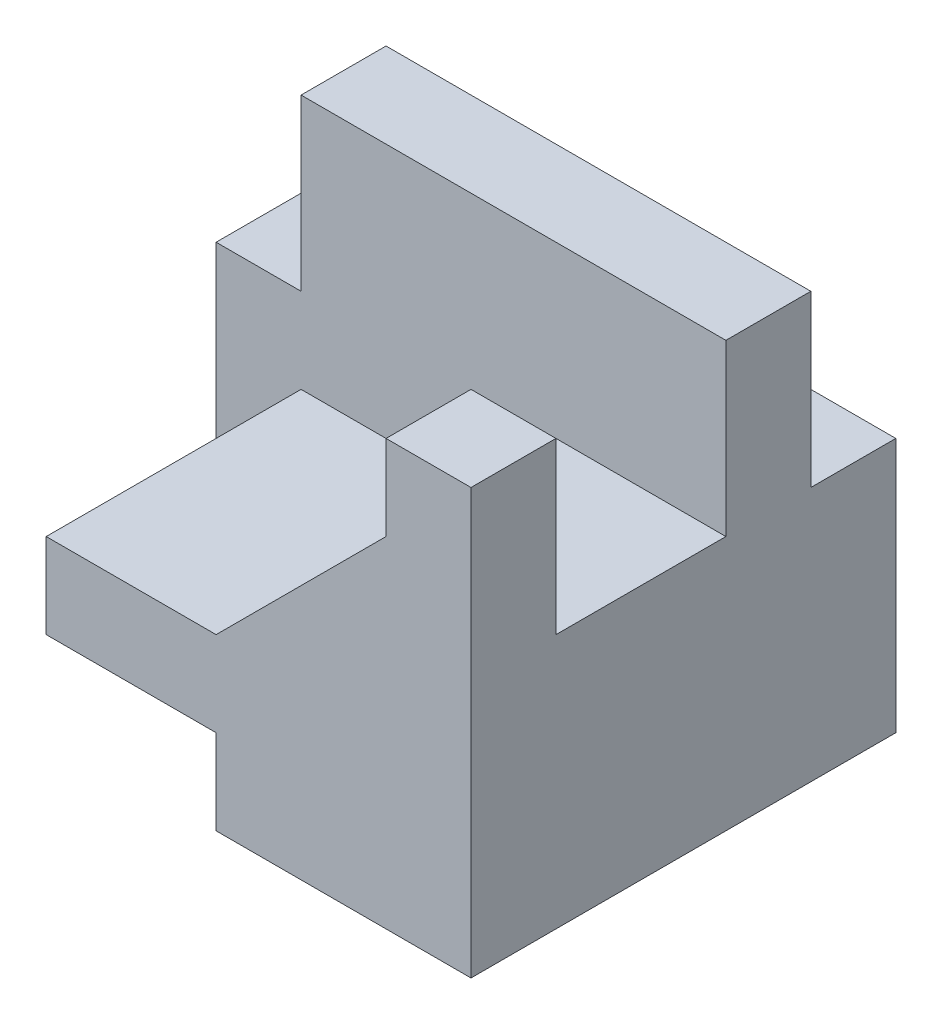
from build123d import *

# Parameters (mm, degrees)
BOSS_EXTRUDE1_DEPTH = 15
SKETCH2_W           = 30
SKETCH2_H           = 25
BOSS_EXTRUDE2_DEPTH = 10
SKETCH3_W           = 5
SKETCH3_H           = 10
CUT_EXTRUDE1_DEPTH  = 15
SKETCH6_W           = 5
SKETCH6_H           = 10
CUT_EXTRUDE4_DEPTH  = 30
SKETCH7_W           = 10
SKETCH7_H           = 10
CUT_EXTRUDE5_DEPTH  = 30


with BuildPart() as part:
    # Sketch1 → Boss-Extrude1 (new body)
    with BuildSketch(Plane.XY):
        Polygon((0, 0), (15, 0), (15, 25), (10, 25), (10, 20), (0, 10), (-10, 10), (-10, 5), (0, 5), align=None)
    extrude(amount=BOSS_EXTRUDE1_DEPTH)

    # Sketch2 → Boss-Extrude2 (add)
    with BuildSketch(Plane(origin=(0, 0, 0), x_dir=(-1, 0, 0), z_dir=(0, 0, -1))):
        with Locations((0, 12.5)):
            Rectangle(SKETCH2_W, SKETCH2_H)
    extrude(amount=BOSS_EXTRUDE2_DEPTH)

    # Sketch3 → Cut-Extrude1 (cut)
    with BuildSketch(Plane.XY):
        with Locations((-12.5, 20)):
            Rectangle(SKETCH3_W, SKETCH3_H)
    extrude(amount=-CUT_EXTRUDE1_DEPTH, mode=Mode.SUBTRACT)

    # Sketch6 → Cut-Extrude4 (cut)
    with BuildSketch(Plane.ZY.offset(10)):
        with Locations((-7.5, 20)):
            Rectangle(SKETCH6_W, SKETCH6_H)
    extrude(amount=-CUT_EXTRUDE4_DEPTH, mode=Mode.SUBTRACT)

    # Sketch7 → Cut-Extrude5 (cut)
    with BuildSketch(Plane.ZY.offset(10)):
        with Locations((5, 20)):
            Rectangle(SKETCH7_W, SKETCH7_H)
    extrude(amount=-CUT_EXTRUDE5_DEPTH, mode=Mode.SUBTRACT)


solid = part.part
